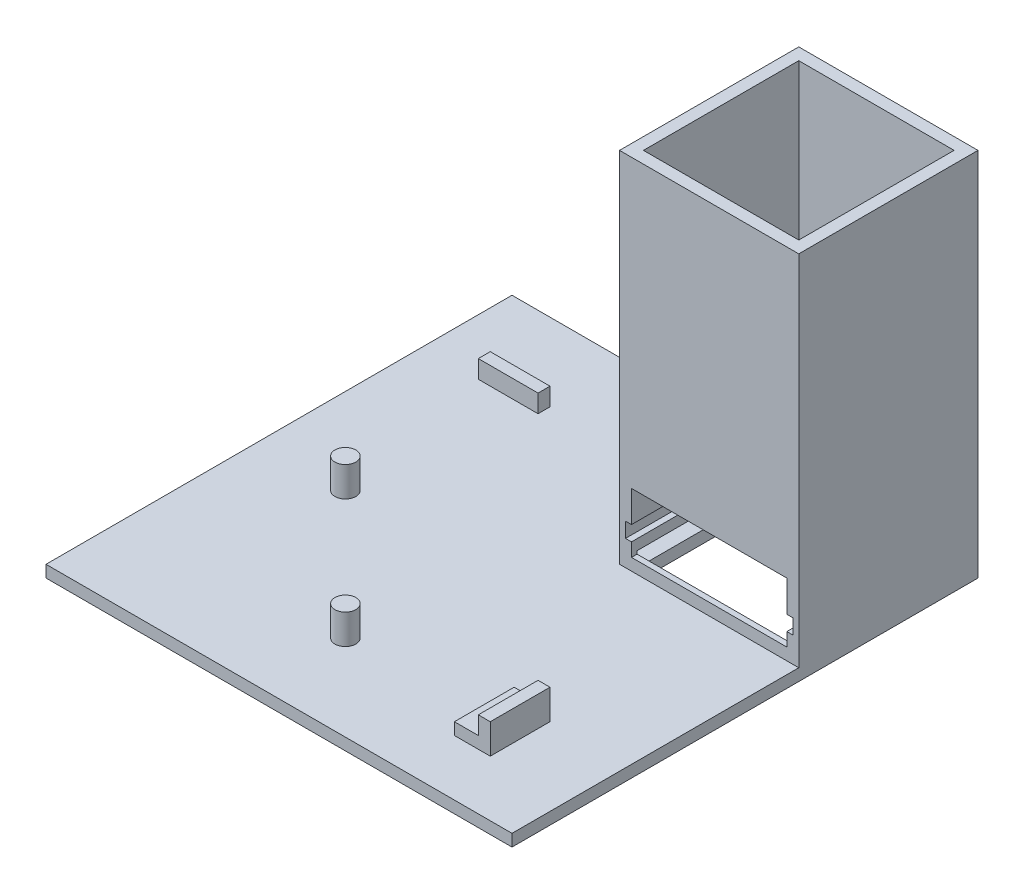
from build123d import *

# Parameters (mm, degrees)
SKETCH1_W            = 78
SKETCH1_H            = 78
BOSS_EXTRUDE1_DEPTH  = 2
SKETCH2_W            = 30
SKETCH2_H            = 30
BOSS_EXTRUDE2_DEPTH  = 60
SKETCH3_W            = 26
SKETCH3_H            = 26
CUT_EXTRUDE1_DEPTH   = 62
SKETCH4_W            = 28
SKETCH4_H            = 2.5
CUT_EXTRUDE2_DEPTH   = 28
SKETCH5_W            = 26
SKETCH5_H            = 10
CUT_EXTRUDE3_DEPTH   = 2
SKETCH6_W            = 28
SKETCH6_H            = 2.5
CUT_EXTRUDE4_DEPTH   = 1
SKETCH7_W            = 28
SKETCH7_H            = 2.5
CUT_EXTRUDE5_DEPTH   = 1
SKETCH14_R           = 1.75
BOSS_EXTRUDE8_DEPTH  = 5
SKETCH15_R           = 1.75
BOSS_EXTRUDE9_DEPTH  = 5
SKETCH16_W           = 4
SKETCH16_H           = 5
BOSS_EXTRUDE10_DEPTH = 2
SKETCH17_W           = 2
SKETCH17_H           = 10
BOSS_EXTRUDE11_DEPTH = 5
SKETCH18_W           = 10
SKETCH18_H           = 2
BOSS_EXTRUDE12_DEPTH = 3


with BuildPart() as part:
    # Sketch1 → Boss-Extrude1 (new body)
    with BuildSketch(Plane(origin=(0, 0, 0), x_dir=(1, 0, 0), z_dir=(0, 1, 0))):
        Rectangle(SKETCH1_W, SKETCH1_H)
    extrude(amount=BOSS_EXTRUDE1_DEPTH)

    # Sketch2 → Boss-Extrude2 (add)
    with BuildSketch(Plane(origin=(0, 2, 0), x_dir=(1, 0, 0), z_dir=(0, 1, 0))):
        with Locations((24, 24)):
            Rectangle(SKETCH2_W, SKETCH2_H)
    extrude(amount=BOSS_EXTRUDE2_DEPTH)

    # Sketch3 → Cut-Extrude1 (cut)
    with BuildSketch(Plane(origin=(0, 62, 0), x_dir=(1, 0, 0), z_dir=(0, 1, 0))):
        with Locations((24, 24)):
            Rectangle(SKETCH3_W, SKETCH3_H)
    extrude(amount=-CUT_EXTRUDE1_DEPTH, mode=Mode.SUBTRACT)

    # Sketch4 → Cut-Extrude2 (cut)
    with BuildSketch(Plane.ZY.offset(-9)):
        with Locations((-23.934548619, 3.25)):
            Rectangle(SKETCH4_W, SKETCH4_H)
    extrude(amount=-CUT_EXTRUDE2_DEPTH, mode=Mode.SUBTRACT)

    # Sketch5 → Cut-Extrude3 (cut)
    with BuildSketch(Plane.XY.offset(-9)):
        with Locations((24, 9)):
            Rectangle(SKETCH5_W, SKETCH5_H)
    extrude(amount=-CUT_EXTRUDE3_DEPTH, mode=Mode.SUBTRACT)

    # Sketch6 → Cut-Extrude4 (cut)
    with BuildSketch(Plane.ZY.offset(-37)):
        with Locations((-23, 7.5)):
            Rectangle(SKETCH6_W, SKETCH6_H)
    extrude(amount=-CUT_EXTRUDE4_DEPTH, mode=Mode.SUBTRACT)

    # Sketch7 → Cut-Extrude5 (cut)
    with BuildSketch(Plane(origin=(11, 0, 0), x_dir=(0, 0, -1), z_dir=(1, 0, 0))):
        with Locations((23, 7.5)):
            Rectangle(SKETCH7_W, SKETCH7_H)
    extrude(amount=-CUT_EXTRUDE5_DEPTH, mode=Mode.SUBTRACT)

    # Sketch14 → Boss-Extrude8 (add)
    with BuildSketch(Plane(origin=(0, 2, 0), x_dir=(1, 0, 0), z_dir=(0, 1, 0))):
        with Locations((-3.25, -24.64)):
            Circle(SKETCH14_R)
    extrude(amount=BOSS_EXTRUDE8_DEPTH)

    # Sketch15 → Boss-Extrude9 (add)
    with BuildSketch(Plane(origin=(0, 2, 0), x_dir=(1, 0, 0), z_dir=(0, 1, 0))):
        with Locations((-24.64, -3.25)):
            Circle(SKETCH15_R)
    extrude(amount=BOSS_EXTRUDE9_DEPTH)

    # Sketch16 → Boss-Extrude10 (add)
    with BuildSketch(Plane(origin=(0, 2, 0), x_dir=(1, 0, 0), z_dir=(0, 1, 0))):
        with Locations((22, -22.14)):
            Rectangle(SKETCH16_W, SKETCH16_H)
        with Locations((22, -27.14)):
            Rectangle(SKETCH16_W, SKETCH16_H)
    extrude(amount=BOSS_EXTRUDE10_DEPTH)

    # Sketch17 → Boss-Extrude11 (add)
    with BuildSketch(Plane(origin=(0, 2, 0), x_dir=(1, 0, 0), z_dir=(0, 1, 0))):
        with Locations((25, -24.64)):
            Rectangle(SKETCH17_W, SKETCH17_H)
    extrude(amount=BOSS_EXTRUDE11_DEPTH)

    # Sketch18 → Boss-Extrude12 (add)
    with BuildSketch(Plane(origin=(0, 2, 0), x_dir=(1, 0, 0), z_dir=(0, 1, 0))):
        with Locations((-24.64, 25)):
            Rectangle(SKETCH18_W, SKETCH18_H)
    extrude(amount=BOSS_EXTRUDE12_DEPTH)


solid = part.part
